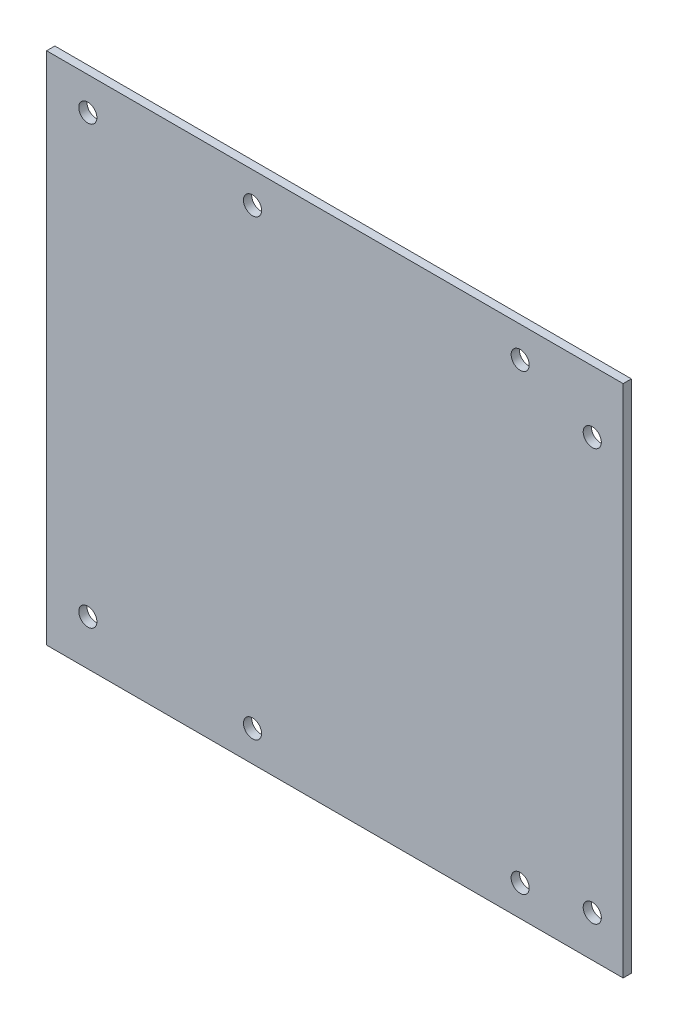
from build123d import *

# Parameters (mm, degrees)
SKETCH_1_W          = 140
SKETCH_1_H          = 125
EXTRUDE_1_DEPTH     = 2
SKETCH_3_R          = 2.2
CUT_EXTRUDE_1_DEPTH = 2
SKETCH_6_R          = 2.2
CUT_EXTRUDE_2_DEPTH = 2
SKETCH_7_R          = 2.2
CUT_EXTRUDE_3_DEPTH = 105


with BuildPart() as part:
    # ｽｹｯﾁ1 → ﾎﾞｽ - 押し出し1 (new body)
    with BuildSketch(Plane.XY):
        Rectangle(SKETCH_1_W, SKETCH_1_H)
    extrude(amount=EXTRUDE_1_DEPTH)

    # ｽｹｯﾁ3 → ｶｯﾄ - 押し出し1 (cut)
    with BuildSketch(Plane.XY.offset(2)):
        with Locations((-60, 54.5)):
            Circle(SKETCH_3_R)
        with Locations((-60, -51.5)):
            Circle(SKETCH_3_R)
    extrude(amount=-CUT_EXTRUDE_1_DEPTH, mode=Mode.SUBTRACT)

    # ｽｹｯﾁ6 → ｶｯﾄ - 押し出し2 (cut)
    with BuildSketch(Plane.XY.offset(2)):
        with Locations((62.5, -52.5)):
            Circle(SKETCH_6_R)
        with Locations((62.5, 47.5)):
            Circle(SKETCH_6_R)
    extrude(amount=-CUT_EXTRUDE_2_DEPTH, mode=Mode.SUBTRACT)

    # ｽｹｯﾁ7 → ｶｯﾄ - 押し出し3 (cut)
    with BuildSketch(Plane.XY.offset(2)):
        with BuildLine():
            ThreePointArc((42.8, 55), (45, 52.8), (47.2, 55))
            Line((47.2, 55), (45, 55))
            Line((45, 55), (42.8, 55))
        make_face()
        with BuildLine():
            Line((45, 55), (47.2, 55))
            ThreePointArc((47.2, 55), (45, 57.2), (42.8, 55))
            Line((42.8, 55), (45, 55))
        make_face()
        with Locations((-20, 55)):
            Circle(SKETCH_7_R)
        with Locations((-20, -55)):
            Circle(SKETCH_7_R)
        with Locations((45, -55)):
            Circle(SKETCH_7_R)
    extrude(amount=-CUT_EXTRUDE_3_DEPTH, mode=Mode.SUBTRACT)


solid = part.part
